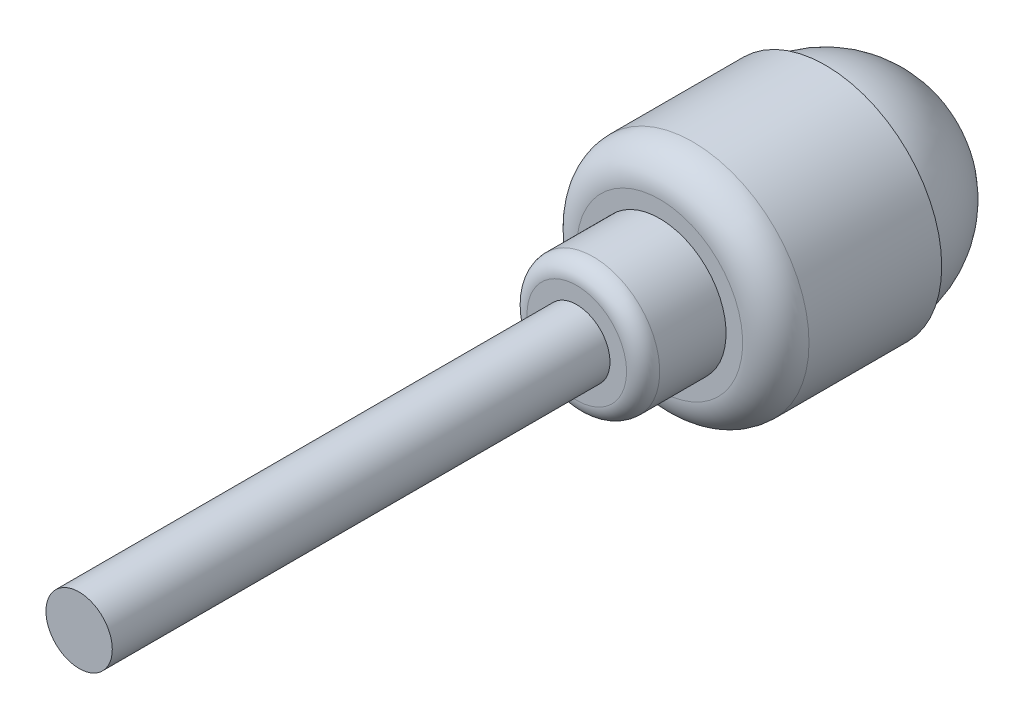
from build123d import *

# Parameters (mm, degrees)
SKETCH2_R           = 2
BOSS_EXTRUDE1_DEPTH = 30
FILLET1_R           = 2
FILLET2_R           = 1


with BuildPart() as part:
    # Sketch1 → Revolve1 (revolve)
    with BuildSketch(Plane(origin=(0, 0, 0), x_dir=(1, 0, 0), z_dir=(0, 1, 0))):
        with BuildLine():
            Line((0, 0), (4, 0))
            Line((4, 0), (4, 5))
            Line((4, 5), (7, 5))
            Line((7, 5), (7, 15))
            Line((7, 15), (6.5, 15))
            ThreePointArc((6.5, 15), (4.596194078, 19.596194078), (0, 21.5))
            Line((0, 21.5), (0, 0))
        make_face()
    revolve(axis=Axis((0, 0, -21.5), (0, 0, 1)))

    # Sketch2 → Boss-Extrude1 (add)
    with BuildSketch(Plane.XY):
        Circle(SKETCH2_R)
    extrude(amount=BOSS_EXTRUDE1_DEPTH)

    # Fillet1
    fillet1_edges = [part.edges().sort_by_distance(p)[0] for p in [
        (-7, 0, -5),
    ]]
    fillet(fillet1_edges, radius=FILLET1_R)

    # Fillet2
    fillet2_edges = [part.edges().sort_by_distance(p)[0] for p in [
        (-4, 0, 0),
    ]]
    fillet(fillet2_edges, radius=FILLET2_R)


solid = part.part
